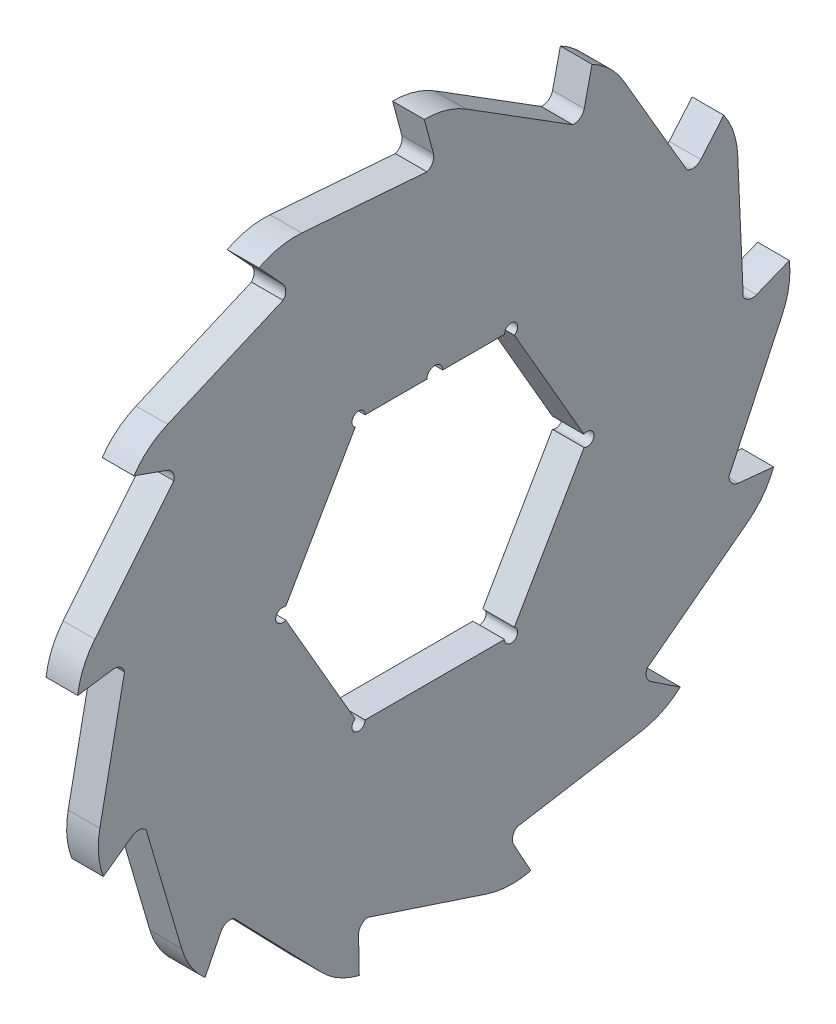
from build123d import *

# Parameters (mm, degrees)
SKETCH1_R                  = 59
EXTRUDE1_DEPTH             = 3
EXTRUDE2_DEPTH             = 3
CIRPATTERN1_COUNT          = 13
F_2_5_2_5_DIAMETER_HOLE1_D = 2.5
F_3_0_3_DIAMETER_HOLE1_D   = 3


with BuildPart() as part:
    # Sketch1 → Extrude1 (new, symmetric)
    with BuildSketch(Plane(origin=(0, 0, 0), x_dir=(0, 0, -1), z_dir=(1, 0, 0))):
        Circle(SKETCH1_R)
        Polygon((14.462624243, 25.05), (-14.462624243, 25.05), (-28.925248486, 0), (-14.462624243, -25.05), (14.462624243, -25.05), (28.925248486, 0), align=None, mode=Mode.SUBTRACT)
    extrude(amount=EXTRUDE1_DEPTH, both=True)

    # Sketch2 → Extrude2 (add, symmetric)
    with BuildSketch(Plane(origin=(0, 0, 0), x_dir=(0, 0, -1), z_dir=(1, 0, 0))):
        with BuildLine():
            Line((-2, 67.961805723), (-0.262709442, 61.478149092))
            ThreePointArc((-0.262709442, 61.478149092), (-0.58620663, 59.77173183), (-2.122608272, 58.961805723))
            ThreePointArc((-2.122608272, 58.961805723), (13.210156106, 57.502102359), (27.642670176, 52.123725745))
            ThreePointArc((27.642670176, 52.123725745), (27.166811562, 52.387250915), (26.700820655, 52.667856348))
            Line((26.700820655, 52.667856348), (5.969647024, 65.669469801))
            ThreePointArc((5.969647024, 65.669469801), (2.146386308, 67.37733487), (-2, 67.961805723))
        make_face()
    extrude2 = extrude(amount=EXTRUDE2_DEPTH, both=True)

    # CirPattern1: Extrude2 ×13 about axis
    cirpattern1_axis = Axis((0, 0, 0), (1, 0, 0))
    for i in range(1, CIRPATTERN1_COUNT):
        add(extrude2.rotate(cirpattern1_axis, i * 360 / CIRPATTERN1_COUNT))

    # Ø2.5 (2.5) Diameter Hole1 (through all)
    with Locations(Plane(origin=(3, 0, 0), x_dir=(0, 0, -1), z_dir=(1, 0, 0))):
        with Locations((-14.462624243, 25.05), (14.462624243, 25.05), (28.925248486, 0), (14.462624243, -25.05), (-14.462624243, -25.05), (-28.925248486, 0)):
            Hole(F_2_5_2_5_DIAMETER_HOLE1_D / 2)

    # Ø3.0 (3) Diameter Hole1 (through all)
    with Locations(Plane(origin=(3, 0, 0), x_dir=(0, 0, -1), z_dir=(1, 0, 0))):
        with Locations((0, 25.05)):
            Hole(F_3_0_3_DIAMETER_HOLE1_D / 2)


solid = part.part
